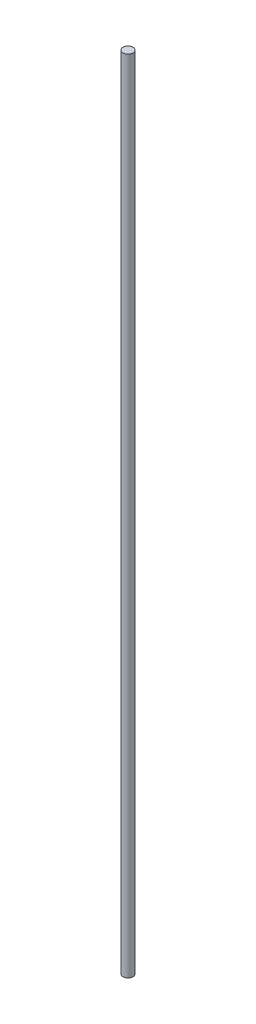
from build123d import *

# Parameters (mm, degrees)
CROQUIS1_R              = 6.35
SALIENTE_EXTRUIR1_DEPTH = 1012


with BuildPart() as part:
    # Croquis1 → Saliente-Extruir1 (new body)
    with BuildSketch(Plane(origin=(0, 0, 0), x_dir=(1, 0, 0), z_dir=(0, 1, 0))):
        Circle(CROQUIS1_R)
    extrude(amount=SALIENTE_EXTRUIR1_DEPTH)


solid = part.part
